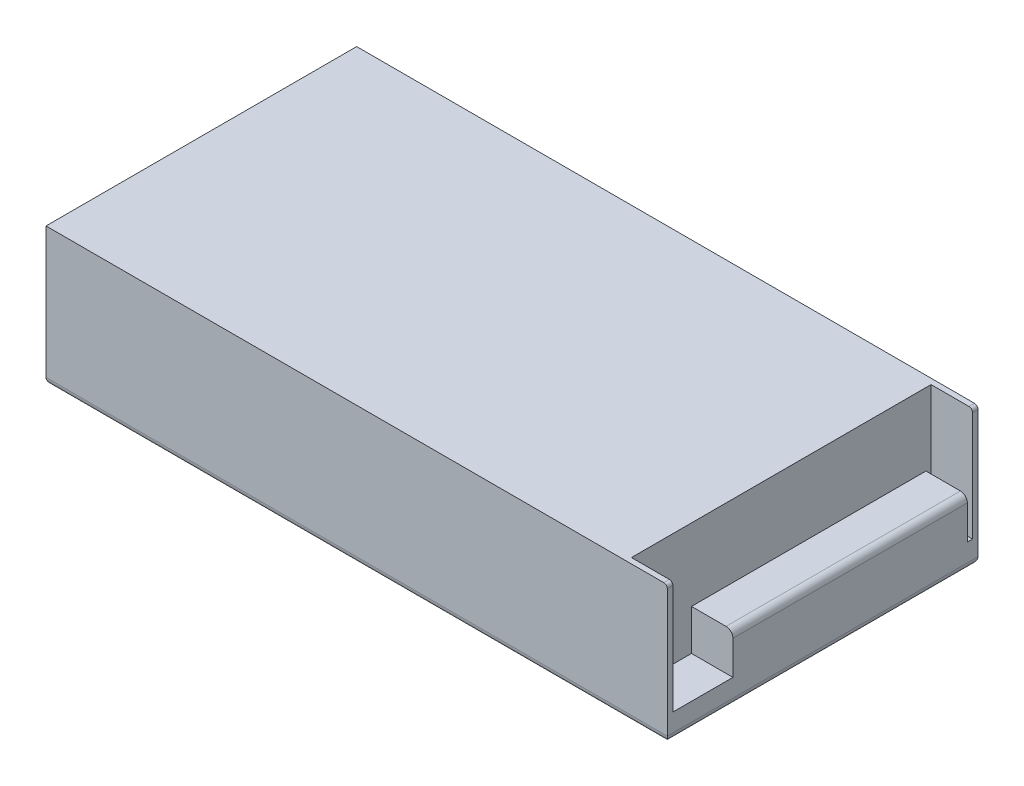
from build123d import *

# Parameters (mm, degrees)
SKETCH1_W           = 228.6
SKETCH1_H           = 114.3
BOSS_EXTRUDE1_DEPTH = 50.8
SKETCH2_W           = 15.24
SKETCH2_H           = 110.236
CUT_EXTRUDE1_DEPTH  = 41.6052
SKETCH3_W           = 15.24
SKETCH3_H           = 86.2584
BOSS_EXTRUDE2_DEPTH = 14.986
FILLET1_R           = 2.54
FILLET2_R           = 1.27
FILLET3_R           = 2.54


with BuildPart() as part:
    # Sketch1 → Boss-Extrude1 (new body)
    with BuildSketch(Plane(origin=(0, 0, 0), x_dir=(1, 0, 0), z_dir=(0, 1, 0))):
        with Locations((60.070744159, -12.437798992)):
            Rectangle(SKETCH1_W, SKETCH1_H)
    extrude(amount=BOSS_EXTRUDE1_DEPTH)

    # Sketch2 → Cut-Extrude1 (cut)
    with BuildSketch(Plane(origin=(0, 50.8, 0), x_dir=(1, 0, 0), z_dir=(0, 1, 0))):
        with Locations((166.750744159, -12.437798992)):
            Rectangle(SKETCH2_W, SKETCH2_H)
    extrude(amount=-CUT_EXTRUDE1_DEPTH, mode=Mode.SUBTRACT)

    # Sketch3 → Boss-Extrude2 (add)
    with BuildSketch(Plane(origin=(0, 9.1948, 0), x_dir=(1, 0, 0), z_dir=(0, 1, 0))):
        with Locations((166.750744159, -2.328598992)):
            Rectangle(SKETCH3_W, SKETCH3_H)
    extrude(amount=BOSS_EXTRUDE2_DEPTH)

    # Fillet1
    fillet1_edges = [part.edges().sort_by_distance(p)[0] for p in [
        (174.370744159, 24.1808, 2.328598992),
    ]]
    fillet(fillet1_edges, radius=FILLET1_R)

    # Fillet2
    fillet2_edges = [part.edges().sort_by_distance(p)[0] for p in [
        (174.370744159, 50.8, 68.571798992),
        (174.370744159, 50.8, -43.696201008),
    ]]
    fillet(fillet2_edges, radius=FILLET2_R)

    # Fillet3
    fillet3_edges = [part.edges().sort_by_distance(p)[0] for p in [
        (60.070744159, 0, -44.712201008),
        (174.370744159, 0, 12.437798992),
        (60.070744159, 0, 69.587798992),
        (-54.229255841, 0, 12.437798992),
    ]]
    fillet(fillet3_edges, radius=FILLET3_R)


solid = part.part
